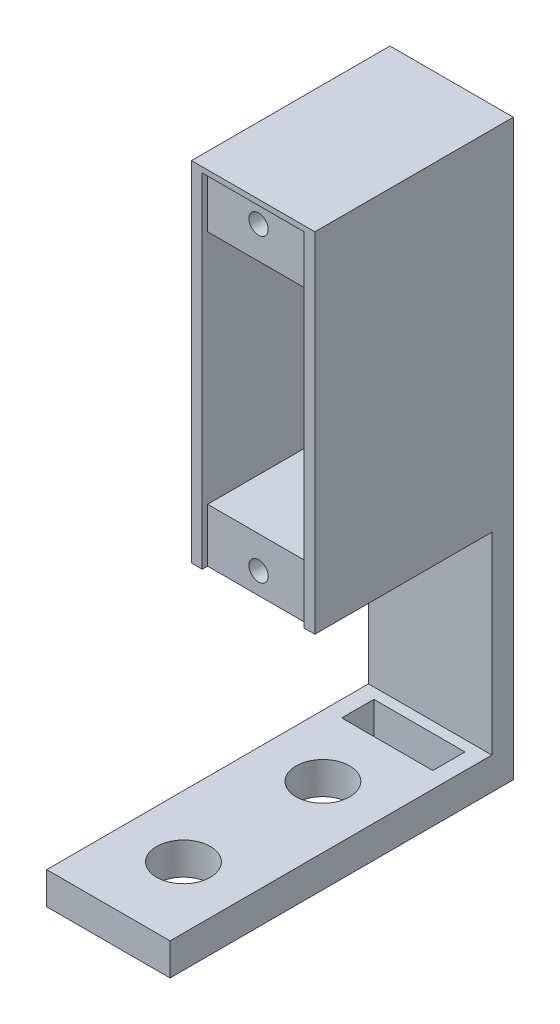
from build123d import *

# Parameters (mm, degrees)
ESQUISSE1_W             = 11.5
ESQUISSE1_H             = 32.5
BOSS_EXTRU_1_DEPTH      = 18.5
ESQUISSE4_W             = 9.5
ESQUISSE4_H             = 32
ENL_V_MAT_EXTRU_1_DEPTH = 16.5
ESQUISSE5_W             = 9.5
ESQUISSE5_H             = 5
BOSS_EXTRU_2_DEPTH      = 16
ESQUISSE6_R             = 0.9
ENL_V_MAT_EXTRU_2_DEPTH = 6
ESQUISSE7_W             = 11.5
ESQUISSE7_H             = 2
BOSS_EXTRU_3_DEPTH      = 21
ESQUISSE9_W             = 9.5
ESQUISSE9_H             = 5
BOSS_EXTRU_4_DEPTH      = 16
ESQUISSE10_R            = 0.9
ENL_V_MAT_EXTRU_3_DEPTH = 7
ESQUISSE11_W            = 9.5
ESQUISSE11_H            = 7
ENL_V_MAT_EXTRU_4_DEPTH = 7
ESQUISSE12_W            = 11.5
ESQUISSE12_H            = 3
BOSS_EXTRU_5_DEPTH      = 30
ESQUISSE13_R            = 2.5
ENL_V_MAT_EXTRU_5_DEPTH = 10
ESQUISSE15_W            = 8.5
ESQUISSE15_H            = 3
ENL_V_MAT_EXTRU_6_DEPTH = 10


with BuildPart() as part:
    # Esquisse1 → Boss.-Extru.1 (new body)
    with BuildSketch(Plane.XY):
        with Locations((-5.75, 16.25)):
            Rectangle(ESQUISSE1_W, ESQUISSE1_H)
    extrude(amount=BOSS_EXTRU_1_DEPTH)

    # Esquisse4 → Enlèv. mat.-Extru.1 (cut)
    with BuildSketch(Plane.XY.offset(18.5)):
        with Locations((-5.75, 16)):
            Rectangle(ESQUISSE4_W, ESQUISSE4_H)
    extrude(amount=-ENL_V_MAT_EXTRU_1_DEPTH, mode=Mode.SUBTRACT)

    # Esquisse5 → Boss.-Extru.2 (add)
    with BuildSketch(Plane.XY.offset(2)):
        with Locations((-5.75, 29.5)):
            Rectangle(ESQUISSE5_W, ESQUISSE5_H)
    extrude(amount=BOSS_EXTRU_2_DEPTH)

    # Esquisse6 → Enlèv. mat.-Extru.2 (cut)
    with BuildSketch(Plane.XY.offset(18)):
        with Locations((-5.75, 30)):
            Circle(ESQUISSE6_R)
    extrude(amount=-ENL_V_MAT_EXTRU_2_DEPTH, mode=Mode.SUBTRACT)

    # Esquisse7 → Boss.-Extru.3 (add)
    with BuildSketch(Plane.XZ):
        with Locations((-5.75, 1)):
            Rectangle(ESQUISSE7_W, ESQUISSE7_H)
    extrude(amount=BOSS_EXTRU_3_DEPTH)

    # Esquisse9 → Boss.-Extru.4 (add)
    with BuildSketch(Plane.XY.offset(2)):
        with Locations((-5.75, 2.5)):
            Rectangle(ESQUISSE9_W, ESQUISSE9_H)
    extrude(amount=BOSS_EXTRU_4_DEPTH)

    # Esquisse10 → Enlèv. mat.-Extru.3 (cut)
    with BuildSketch(Plane.XY.offset(18)):
        with Locations((-5.75, 2)):
            Circle(ESQUISSE10_R)
    extrude(amount=-ENL_V_MAT_EXTRU_3_DEPTH, mode=Mode.SUBTRACT)

    # Esquisse11 → Enlèv. mat.-Extru.4 (cut)
    with BuildSketch(Plane.XZ):
        with Locations((-5.75, 5.5)):
            Rectangle(ESQUISSE11_W, ESQUISSE11_H)
    extrude(amount=-ENL_V_MAT_EXTRU_4_DEPTH, mode=Mode.SUBTRACT)

    # Esquisse12 → Boss.-Extru.5 (add)
    with BuildSketch(Plane.XY.offset(2)):
        with Locations((-5.75, -19.5)):
            Rectangle(ESQUISSE12_W, ESQUISSE12_H)
    extrude(amount=BOSS_EXTRU_5_DEPTH)

    # Esquisse13 → Enlèv. mat.-Extru.5 (cut)
    with BuildSketch(Plane.XZ.offset(21)):
        with Locations((-5.75, 12)):
            Circle(ESQUISSE13_R)
        with Locations((-5.75, 25)):
            Circle(ESQUISSE13_R)
    extrude(amount=-ENL_V_MAT_EXTRU_5_DEPTH, mode=Mode.SUBTRACT)

    # Esquisse15 → Enlèv. mat.-Extru.6 (cut)
    with BuildSketch(Plane.XZ.offset(21)):
        with Locations((-5.75, 4.5)):
            Rectangle(ESQUISSE15_W, ESQUISSE15_H)
    extrude(amount=-ENL_V_MAT_EXTRU_6_DEPTH, mode=Mode.SUBTRACT)


solid = part.part
